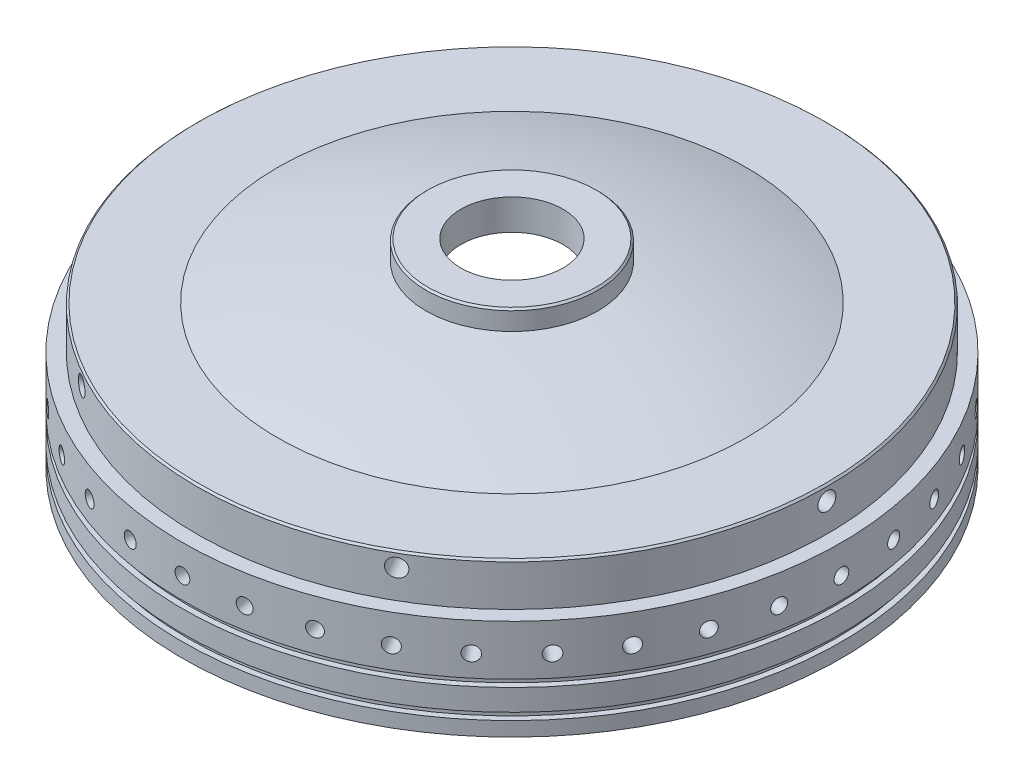
from build123d import *

# Parameters (mm, degrees)
SKETCH2_R                       = 38.1
BOSS_EXTRUDE1_DEPTH             = 6.35
BOSS_EXTRUDE1_DIRECTION_2_REACH = 83.727
CIRPATTERN1_COUNT               = 36
F_2_4_5_TAPPED_HOLE1_D          = 45.24248
F_2_4_5_TAPPED_HOLE1_DEPTH      = 118.618
F_2_4_5_TAPPED_HOLE1_TIP        = 13.59221227
CHAMFER2_SIZE                   = 0.79375
CIRPATTERN2_COUNT               = 6


with BuildPart() as part:
    # Sketch1 → Revolve1 (revolve)
    with BuildSketch(Plane.XY):
        with BuildLine():
            Line((0, 81.727348484), (0, 75.377348484))
            ThreePointArc((0, 75.377348484), (67.208178416, 67.540379415), (130.81, 44.45))
            Line((130.81, 44.45), (130.81, 22.225))
            Line((130.81, 22.225), (136.525, 22.225))
            Line((136.525, 22.225), (136.525, 0))
            Line((136.525, 0), (146.05, 0))
            Line((146.05, 0), (146.05, 6.35))
            Line((146.05, 6.35), (143.51, 6.35))
            Line((143.51, 6.35), (143.51, 9.525))
            Line((143.51, 9.525), (146.05, 9.525))
            Line((146.05, 9.525), (146.05, 19.05))
            Line((146.05, 19.05), (143.51, 19.05))
            Line((143.51, 19.05), (143.51, 22.225))
            Line((143.51, 22.225), (146.05, 22.225))
            Line((146.05, 22.225), (146.05, 44.45))
            Line((146.05, 44.45), (139.622896369, 44.45))
            Line((139.622896369, 44.45), (139.622896369, 63.5))
            Line((139.622896369, 63.5), (103.822711403, 63.5))
            ThreePointArc((103.822711403, 63.5), (52.705292988, 77.135929459), (0, 81.727348484))
        make_face()
    revolve(axis=Axis((0, 81.727348484, 0), (0, -1, 0)))

    # Sketch2 → Boss-Extrude1 (add)
    with BuildSketch(Plane(origin=(0, 81.727348484, 0), x_dir=(1, 0, 0), z_dir=(0, 1, 0))):
        Circle(SKETCH2_R)
    extrude(amount=BOSS_EXTRUDE1_DEPTH)

    # Sketch2 → Boss-Extrude1 direction 2 (add, up to next)
    with BuildSketch(Plane(origin=(0, 81.727348484, 0), x_dir=(1, 0, 0), z_dir=(0, 1, 0)), mode=Mode.PRIVATE) as boss_extrude1_direction_2_sk1:
        Circle(SKETCH2_R)
    boss_extrude1_direction_2_tool1 = extrude(boss_extrude1_direction_2_sk1.sketch, amount=-BOSS_EXTRUDE1_DIRECTION_2_REACH, mode=Mode.PRIVATE) - part.part
    add(boss_extrude1_direction_2_tool1.solids().sort_by_distance((0, 81.727348, 0))[0])

    # Sketch5 → 5/16-18 Tapped Hole1 (revolve, cut)
    with BuildSketch(Plane(origin=(-146.05, 31.75, 0), x_dir=(0, 0, 1), z_dir=(0, 1, 0))):
        Polygon((0, 0), (0, 14.661148974), (3.2639, 12.7), (3.2639, 0), align=None)
    f_5_16_18_tapped_hole1 = revolve(axis=Axis((-152.4, 31.75, 0), (1, 0, 0)), mode=Mode.SUBTRACT)

    # CirPattern1: 5/16-18 Tapped Hole1 ×36 about axis
    cirpattern1_axis = Axis((0, 44.45, 0), (0, 1, 0))
    for i in range(1, CIRPATTERN1_COUNT):
        add(f_5_16_18_tapped_hole1.rotate(cirpattern1_axis, i * 360 / CIRPATTERN1_COUNT), mode=Mode.SUBTRACT)

    # Sketch7 → 3/8-16 Tapped Hole2 (revolve, cut)
    with BuildSketch(Plane(origin=(-139.622896369, 57.15, 0), x_dir=(0, 0, 1), z_dir=(0, 1, 0))):
        Polygon((0, 0), (0, 26.260665582), (3.96875, 23.876), (3.96875, 0), align=None)
    f_3_8_16_tapped_hole2 = revolve(axis=Axis((-145.972896369, 57.15, 0), (1, 0, 0)), mode=Mode.SUBTRACT)

    # 2-4.5 Tapped Hole1
    with Locations(Plane(origin=(0, 88.077348484, 0), x_dir=(1, 0, 0), z_dir=(0, 1, 0))):
        with Locations((0, 0)):
            Hole(F_2_4_5_TAPPED_HOLE1_D / 2, depth=F_2_4_5_TAPPED_HOLE1_DEPTH)
            with Locations((0, 0, -(F_2_4_5_TAPPED_HOLE1_DEPTH + F_2_4_5_TAPPED_HOLE1_TIP / 2))):  # 118° drill point
                Cone(0, F_2_4_5_TAPPED_HOLE1_D / 2, F_2_4_5_TAPPED_HOLE1_TIP, mode=Mode.SUBTRACT)

    # Chamfer2
    chamfer2_edges = [part.edges().sort_by_distance(p)[0] for p in [
        (-139.622896369, 63.5, 0),
        (-38.1, 88.077348484, 0),
    ]]
    chamfer(chamfer2_edges, length=CHAMFER2_SIZE)

    # CirPattern2: 3/8-16 Tapped Hole2 ×6 about axis
    cirpattern2_axis = Axis((0, 63.5, 0), (0, -1, 0))
    for i in range(1, CIRPATTERN2_COUNT):
        add(f_3_8_16_tapped_hole2.rotate(cirpattern2_axis, i * 360 / CIRPATTERN2_COUNT), mode=Mode.SUBTRACT)


solid = part.part
